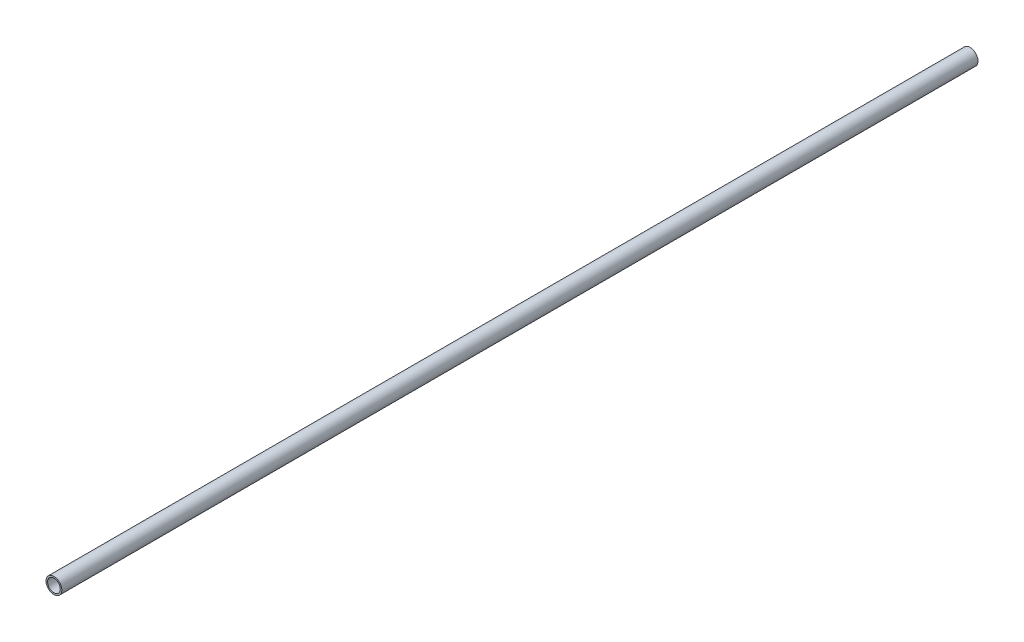
from build123d import *

# Parameters (mm, degrees)
SKETCH3_R                = 15.7988
SKETCH3_R_2              = 12.7
BOSS_EXTRUDE1_DEPTH      = 914.4
BOSS_EXTRUDE1_DEPTH_BACK = 914.4


with BuildPart() as part:
    # Sketch3 → Boss-Extrude1 (new body, two sides)
    with BuildSketch(Plane.XY) as boss_extrude1_sk:
        Circle(SKETCH3_R)
        Circle(SKETCH3_R_2, mode=Mode.SUBTRACT)
    extrude(amount=BOSS_EXTRUDE1_DEPTH)
    extrude(boss_extrude1_sk.sketch, amount=-BOSS_EXTRUDE1_DEPTH_BACK)


solid = part.part
